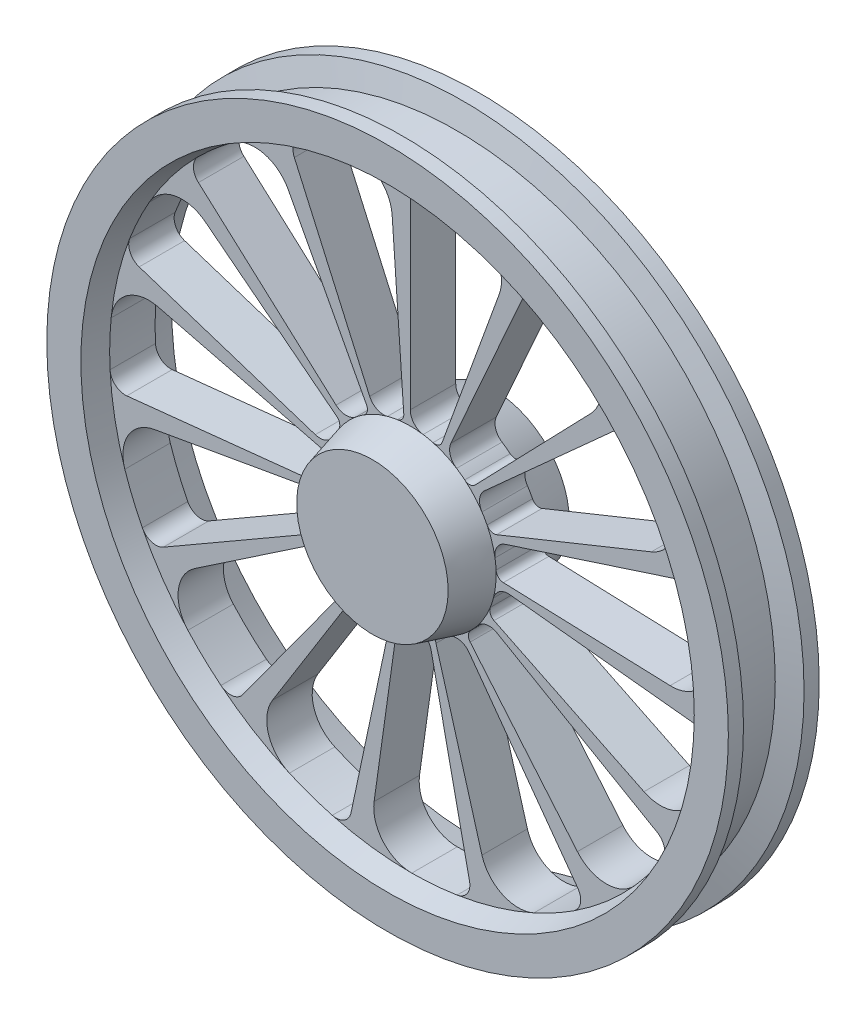
from build123d import *

# Parameters (mm, degrees)
CUT_EXTRUDE1_DEPTH      = 51
CUT_EXTRUDE1_DEPTH_BACK = 111


with BuildPart() as part:
    # Sketch1 → Revolve1 (revolve)
    with BuildSketch(Plane(origin=(0, 0, 0), x_dir=(0, 0, -1), z_dir=(1, 0, 0))):
        Polygon((-80, 0), (-80, 100), (-30, 113.397459622), (-30, 396.961524227), (-60, 405), (-60, 450), (-40, 450), (-31.961524227, 420), (31.961524227, 420), (40, 450), (60, 450), (60, 405), (30, 396.961524227), (30, 113.397459622), (80, 100), (80, 0), align=None)
    revolve(axis=Axis((0, 0, 80), (0, 0, -1)))

    # Sketch3 → Cut-Extrude1 (cut, two sides)
    with BuildSketch(Plane.XY.offset(30)) as cut_extrude1_sk:
        with BuildLine():
            Line((0, 131.889659312), (0, 376.430592205))
            ThreePointArc((0, 376.430592205), (6.238138299, 390.943040741), (21.061116253, 396.402423175))
            ThreePointArc((21.061116253, 396.402423175), (50.974577896, 393.675048898), (80.596172194, 388.693592363))
            ThreePointArc((80.596172194, 388.693592363), (114.114962672, 364.084407568), (117.429167965, 322.633987368))
            Line((117.429167965, 322.633987368), (42.065603785, 115.574296534))
            ThreePointArc((42.065603785, 115.574296534), (37.258917189, 110.110259097), (30.021242396, 109.351309336))
            ThreePointArc((30.021242396, 109.351309336), (23.551936394, 110.924704826), (17.001442148, 112.115720635))
            ThreePointArc((17.001442148, 112.115720635), (4.834724581, 118.850701475), (0, 131.889659312))
        make_face()
        with BuildLine():
            Line((53.644357285, 120.487199175), (153.108115424, 343.886457626))
            ThreePointArc((153.108115424, 343.886457626), (164.709682932, 354.606959635), (180.471677995, 353.565305366))
            ThreePointArc((180.471677995, 353.565305366), (206.689661944, 338.906824012), (231.724193954, 322.307849195))
            ThreePointArc((231.724193954, 322.307849195), (252.335675529, 286.19291989), (238.503947953, 246.978068064))
            Line((238.503947953, 246.978068064), (85.437142658, 88.472751146))
            ThreePointArc((85.437142658, 88.472751146), (78.823591708, 85.436160136), (71.902954099, 87.686652578))
            ThreePointArc((71.902954099, 87.686652578), (66.632906586, 91.755324687), (61.133162095, 95.50769781))
            ThreePointArc((61.133162095, 95.50769781), (52.757676025, 106.609058824), (53.644357285, 120.487199175))
        make_face()
        with BuildLine():
            Line((98.013117852, 88.251407708), (279.742446748, 251.881230414))
            ThreePointArc((279.742446748, 251.881230414), (294.701427046, 256.956113705), (308.677047078, 249.593534219))
            ThreePointArc((308.677047078, 249.593534219), (326.666225725, 225.538530383), (342.784997432, 200.192150827))
            ThreePointArc((342.784997432, 200.192150827), (346.925257689, 158.816076382), (318.3392286, 128.617397067))
            Line((318.3392286, 128.617397067), (114.035823395, 46.073463336))
            ThreePointArc((114.035823395, 46.073463336), (106.758951131, 45.989372924), (101.351991821, 50.860176981))
            ThreePointArc((101.351991821, 50.860176981), (98.192441889, 56.720615339), (94.694402938, 62.385526373))
            ThreePointArc((94.694402938, 62.385526373), (91.558345996, 75.933741389), (98.013117852, 88.251407708))
        make_face()
        with BuildLine():
            Line((125.434519921, 40.75614611), (358.006767649, 116.323450194))
            ThreePointArc((358.006767649, 116.323450194), (373.736617145, 114.875221343), (383.509350478, 102.46477352))
            ThreePointArc((383.509350478, 102.46477352), (390.159231408, 73.172575897), (394.575160749, 43.461410891))
            ThreePointArc((394.575160749, 43.461410891), (381.528311077, 3.978490469), (343.130764601, -11.982390336))
            Line((343.130764601, -11.982390336), (122.916674283, -4.292344849))
            ThreePointArc((122.916674283, -4.292344849), (116.234718028, -1.409394667), (113.276349403, 5.239514734))
            ThreePointArc((113.276349403, 5.239514734), (112.773611939, 11.878396309), (111.882121242, 18.476330672))
            ThreePointArc((111.882121242, 18.476330672), (114.527746163, 32.128790232), (125.434519921, 40.75614611))
        make_face()
        with BuildLine():
            Line((131.167153959, -13.786223409), (374.368466034, -39.34771133))
            ThreePointArc((374.368466034, -39.34771133), (388.149350849, -47.068640399), (392.029403108, -62.381077384))
            ThreePointArc((392.029403108, -62.381077384), (386.190161496, -91.845581713), (378.13969417, -120.784201822))
            ThreePointArc((378.13969417, -120.784201822), (350.161653404, -151.54701259), (308.591874157, -150.510313593))
            Line((308.591874157, -150.510313593), (110.544115525, -53.915967616))
            ThreePointArc((110.544115525, -53.915967616), (105.61244622, -48.564465115), (105.614197089, -41.287107211))
            ThreePointArc((105.614197089, -41.287107211), (107.855199968, -35.017705356), (109.724404365, -28.627590455))
            ThreePointArc((109.724404365, -28.627590455), (117.694258566, -17.231520638), (131.167153959, -13.786223409))
        make_face()
        with BuildLine():
            Line((114.219795461, -65.944829656), (325.998455611, -188.215296102))
            ThreePointArc((325.998455611, -188.215296102), (335.447535565, -200.87390661), (332.764010465, -216.440673294))
            ThreePointArc((332.764010465, -216.440673294), (315.445304234, -240.982803855), (296.320439178, -264.14512875))
            ThreePointArc((296.320439178, -264.14512875), (258.248864739, -280.86866041), (220.694645203, -263.013636287))
            Line((220.694645203, -263.013636287), (79.057474931, -94.21702977))
            ThreePointArc((79.057474931, -94.21702977), (76.728823001, -87.322298352), (79.690390624, -80.674813237))
            ThreePointArc((79.690390624, -80.674813237), (84.28764409, -75.858927638), (88.59434116, -70.781541119))
            ThreePointArc((88.59434116, -70.781541119), (100.510364444, -63.612345045), (114.219795461, -65.944829656))
        make_face()
        with BuildLine():
            Line((77.522796674, -106.700975766), (221.26035061, -304.538746296))
            ThreePointArc((221.26035061, -304.538746296), (224.743793937, -319.946249486), (215.960697346, -333.07571049))
            ThreePointArc((215.960697346, -333.07571049), (190.157088139, -348.451909949), (163.264688265, -361.832963234))
            ThreePointArc((163.264688265, -361.832963234), (121.682501243, -361.625565234), (94.637307145, -330.039511862))
            Line((94.637307145, -330.039511862), (33.901078706, -118.227111542))
            ThreePointArc((33.901078706, -118.227111542), (34.578089225, -110.981312904), (39.987391656, -106.113111146))
            ThreePointArc((39.987391656, -106.113111146), (46.145988819, -103.583452175), (52.145511513, -100.696720293))
            ThreePointArc((52.145511513, -100.696720293), (65.947315202, -98.994017095), (77.522796674, -106.700975766))
        make_face()
        with BuildLine():
            Line((27.421402069, -129.007553818), (78.264320901, -368.204680608))
            ThreePointArc((78.264320901, -368.204680608), (75.179808604, -383.696979206), (61.815817715, -392.118931444))
            ThreePointArc((61.815817715, -392.118931444), (31.988983981, -395.670515228), (1.978989538, -396.956591225))
            ThreePointArc((1.978989538, -396.956591225), (-35.923872168, -379.854124564), (-47.783681072, -339.998557522))
            Line((-47.783681072, -339.998557522), (-17.117122008, -121.794651669))
            ThreePointArc((-17.117122008, -121.794651669), (-13.551510309, -115.450650223), (-6.629790604, -113.203488132))
            ThreePointArc((-6.629790604, -113.203488132), (0.025272858, -113.397456805), (6.680249199, -113.200521727))
            ThreePointArc((6.680249199, -113.200521727), (19.981376049, -117.258724256), (27.421402069, -129.007553818))
        make_face()
        with BuildLine():
            Line((-27.421402069, -129.007553818), (-78.264320901, -368.204680608))
            ThreePointArc((-78.264320901, -368.204680608), (-87.383448624, -381.103015443), (-103.017578378, -383.361226863))
            ThreePointArc((-103.017578378, -383.361226863), (-131.710306117, -374.474093869), (-159.648894458, -363.442818356))
            ThreePointArc((-159.648894458, -363.442818356), (-187.318681724, -332.40245489), (-181.94243673, -291.168763797))
            Line((-181.94243673, -291.168763797), (-65.175616823, -104.302790053))
            ThreePointArc((-65.175616823, -104.302790053), (-59.337930599, -99.957521281), (-52.100621838, -100.719953597))
            ThreePointArc((-52.100621838, -100.719953597), (-46.09981301, -103.60401097), (-39.94008889, -106.13092456))
            ThreePointArc((-39.94008889, -106.13092456), (-29.439524548, -115.248332731), (-27.421402069, -129.007553818))
        make_face()
        with BuildLine():
            Line((-77.522796674, -106.700975766), (-221.26035061, -304.538746296))
            ThreePointArc((-221.26035061, -304.538746296), (-234.837313731, -312.612878098), (-250.038299284, -308.31688343))
            ThreePointArc((-250.038299284, -308.31688343), (-272.635687737, -288.527699691), (-293.672034238, -267.08648042))
            ThreePointArc((-293.672034238, -267.08648042), (-306.324389472, -227.475380984), (-284.641692182, -191.993245625))
            Line((-284.641692182, -191.993245625), (-101.964655387, -68.776028475))
            ThreePointArc((-101.964655387, -68.776028475), (-94.864283621, -67.180828824), (-88.562782238, -70.821024074))
            ThreePointArc((-88.562782238, -70.821024074), (-84.253822405, -75.896490425), (-79.654422766, -80.710326368))
            ThreePointArc((-79.654422766, -80.710326368), (-73.770063901, -93.310457479), (-77.522796674, -106.700975766))
        make_face()
        with BuildLine():
            Line((-114.219795461, -65.944829656), (-325.998455611, -188.215296102))
            ThreePointArc((-325.998455611, -188.215296102), (-341.685673864, -190.069134131), (-353.825126717, -179.961749881))
            ThreePointArc((-353.825126717, -179.961749881), (-366.41988213, -152.692245044), (-376.916611372, -124.548463614))
            ThreePointArc((-376.916611372, -124.548463614), (-372.363827412, -83.215747158), (-338.123813167, -59.620351081))
            Line((-338.123813167, -59.620351081), (-121.123078715, -21.357266764))
            ThreePointArc((-121.123078715, -21.357266764), (-113.98774019, -22.787960745), (-109.711633021, -28.6764961))
            ThreePointArc((-109.711633021, -28.6764961), (-107.839580483, -35.065777188), (-105.595783307, -41.334179516))
            ThreePointArc((-105.595783307, -41.334179516), (-105.345089026, -55.23835643), (-114.219795461, -65.944829656))
        make_face()
        with BuildLine():
            Line((-131.167153959, -13.786223409), (-374.368466034, -39.34771133))
            ThreePointArc((-374.368466034, -39.34771133), (-389.453476869, -34.660710149), (-396.432375341, -20.489594876))
            ThreePointArc((-396.432375341, -20.489594876), (-396.846750083, 9.545085937), (-394.988882219, 39.525114038))
            ThreePointArc((-394.988882219, 39.525114038), (-374.018176772, 75.432645344), (-333.141255098, 83.061443798))
            Line((-333.141255098, 83.061443798), (-119.338221365, 29.754360396))
            ThreePointArc((-119.338221365, 29.754360396), (-113.401680933, 25.545152769), (-111.890345755, 18.426458568))
            ThreePointArc((-111.890345755, 18.426458568), (-112.778895405, 11.828127488), (-113.278673608, 5.189022483))
            ThreePointArc((-113.278673608, 5.189022483), (-118.704991228, -7.615041729), (-131.167153959, -13.786223409))
        make_face()
        with BuildLine():
            Line((-125.434519921, 40.75614611), (-358.006767649, 116.323450194))
            ThreePointArc((-358.006767649, 116.323450194), (-369.88123565, 126.740865501), (-370.492864793, 142.525397225))
            ThreePointArc((-370.492864793, 142.525397225), (-358.655209706, 170.131984845), (-344.76398697, 196.764440399))
            ThreePointArc((-344.76398697, 196.764440399), (-311.00138552, 221.038048182), (-270.555547528, 211.381160456))
            Line((-270.555547528, 211.381160456), (-96.918701387, 75.721188333))
            ThreePointArc((-96.918701387, 75.721188333), (-93.207440822, 69.461277299), (-94.722201217, 62.34331115))
            ThreePointArc((-94.722201217, 62.34331115), (-98.217714747, 56.676841466), (-101.374652137, 50.814995354))
            ThreePointArc((-101.374652137, 50.814995354), (-111.539722045, 41.324982867), (-125.434519921, 40.75614611))
        make_face()
        with BuildLine():
            Line((-98.013117852, 88.251407708), (-279.742446748, 251.881230414))
            ThreePointArc((-279.742446748, 251.881230414), (-286.353168521, 266.227794101), (-280.4917721, 280.896453343))
            ThreePointArc((-280.4917721, 280.896453343), (-258.448925292, 301.301517972), (-234.926266291, 319.981407465))
            ThreePointArc((-234.926266291, 319.981407465), (-194.209629353, 328.423964421), (-161.188327871, 303.151154133))
            Line((-161.188327871, 303.151154133), (-57.74105746, 108.595134902))
            ThreePointArc((-57.74105746, 108.595134902), (-56.896787429, 101.366915948), (-61.175727564, 95.480438864))
            ThreePointArc((-61.175727564, 95.480438864), (-66.673798929, 91.725614661), (-71.942032351, 87.654593889))
            ThreePointArc((-71.942032351, 87.654593889), (-85.088221615, 83.119542499), (-98.013117852, 88.251407708))
        make_face()
        with BuildLine():
            Line((-53.644357285, 120.487199175), (-153.108115424, 343.886457626))
            ThreePointArc((-153.108115424, 343.886457626), (-153.312037118, 359.681518497), (-141.991103824, 370.697960814))
            ThreePointArc((-141.991103824, 370.697960814), (-113.554473759, 380.373281404), (-84.467659932, 387.870682241))
            ThreePointArc((-84.467659932, 387.870682241), (-43.837263932, 379.022393574), (-23.950181975, 342.503559218))
            Line((-23.950181975, 342.503559218), (-8.579460138, 122.691996091))
            ThreePointArc((-8.579460138, 122.691996091), (-10.748162599, 115.74529394), (-17.051414851, 112.108131285))
            ThreePointArc((-17.051414851, 112.108131285), (-23.601377564, 110.914195781), (-30.0699816, 109.337916823))
            ThreePointArc((-30.0699816, 109.337916823), (-43.924194665, 110.541978117), (-53.644357285, 120.487199175))
        make_face()
    extrude(amount=CUT_EXTRUDE1_DEPTH, mode=Mode.SUBTRACT)
    extrude(cut_extrude1_sk.sketch, amount=-CUT_EXTRUDE1_DEPTH_BACK, mode=Mode.SUBTRACT)


solid = part.part
